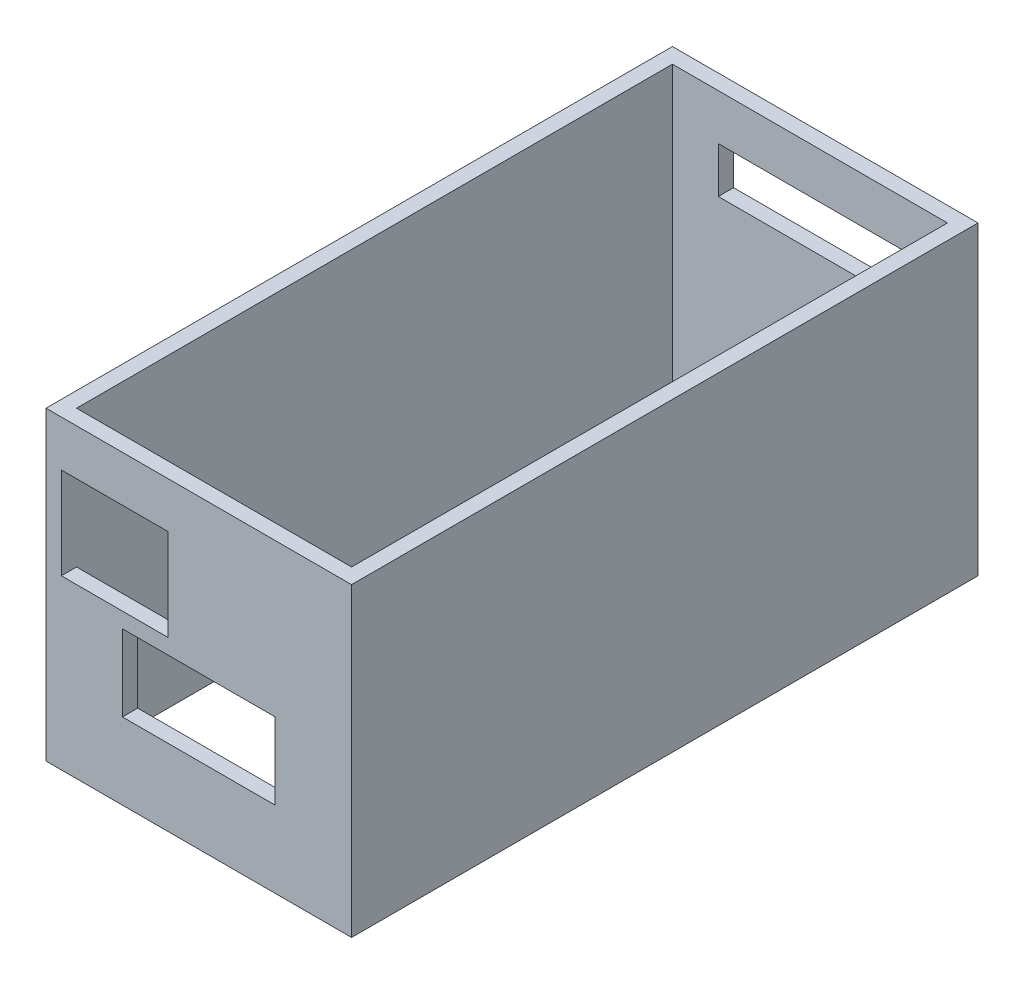
from build123d import *

# Parameters (mm, degrees)
SKETCH1_W           = 40
SKETCH1_H           = 82
SKETCH1_W_2         = 36
SKETCH1_H_2         = 78
BOSS_EXTRUDE1_DEPTH = 40
SKETCH2_W           = 20
SKETCH2_H           = 10
SKETCH2_W_2         = 14
SKETCH2_H_2         = 12
CUT_EXTRUDE1_DEPTH  = 20
SKETCH4_W           = 36
SKETCH4_H           = 36
SKETCH4_W_2         = 32
SKETCH4_H_2         = 32
BOSS_EXTRUDE2_DEPTH = 2
SKETCH3_W           = 24
SKETCH3_H           = 6
CUT_EXTRUDE2_DEPTH  = 2


with BuildPart() as part:
    # Sketch1 → Boss-Extrude1 (new body)
    with BuildSketch(Plane(origin=(0, 0, 0), x_dir=(1, 0, 0), z_dir=(0, 1, 0))):
        with Locations((18, 39)):
            Rectangle(SKETCH1_W, SKETCH1_H)
        with Locations((18, 39)):
            Rectangle(SKETCH1_W_2, SKETCH1_H_2, mode=Mode.SUBTRACT)
    extrude(amount=BOSS_EXTRUDE1_DEPTH)

    # Sketch2 → Cut-Extrude1 (cut)
    with BuildSketch(Plane.XY.offset(2)):
        with Locations((18, 15)):
            Rectangle(SKETCH2_W, SKETCH2_H)
        with Locations((7, 28)):
            Rectangle(SKETCH2_W_2, SKETCH2_H_2)
    extrude(amount=-CUT_EXTRUDE1_DEPTH, mode=Mode.SUBTRACT)

    # Sketch4 → Boss-Extrude2 (add)
    with BuildSketch(Plane(origin=(0, 0, -80), x_dir=(-1, 0, 0), z_dir=(0, 0, -1))):
        with Locations((-18, 20)):
            Rectangle(SKETCH4_W, SKETCH4_H)
        with Locations((-18, 20)):
            Rectangle(SKETCH4_W_2, SKETCH4_H_2, mode=Mode.SUBTRACT)
    extrude(amount=BOSS_EXTRUDE2_DEPTH)

    # Sketch3 → Cut-Extrude2 (cut)
    with BuildSketch(Plane(origin=(0, 0, -80), x_dir=(-1, 0, 0), z_dir=(0, 0, -1))):
        with Locations((-18, 31)):
            Rectangle(SKETCH3_W, SKETCH3_H)
    extrude(amount=-CUT_EXTRUDE2_DEPTH, mode=Mode.SUBTRACT)


solid = part.part
